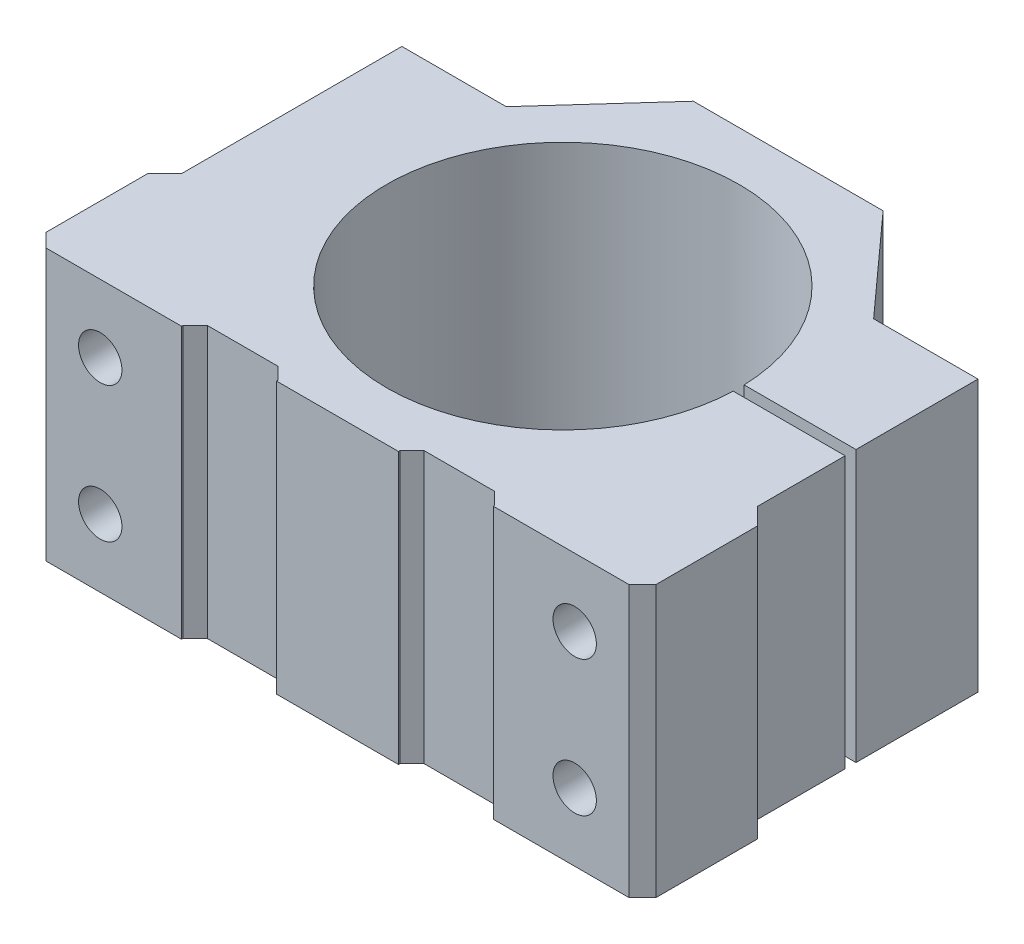
from build123d import *

# Parameters (mm, degrees)
CROQUIS1_R              = 26
SALIENTE_EXTRUIR1_DEPTH = 40
CROQUIS2_R              = 3.2
CORTAR_EXTRUIR1_DEPTH   = 67.5
CORTAR_EXTRUIR2_REACH   = 89.5
CROQUIS3_W              = 1.6
CROQUIS3_H              = 40


with BuildPart() as part:
    # Croquis1 → Saliente-Extruir1 (new body)
    with BuildSketch(Plane(origin=(0, 0, 0), x_dir=(1, 0, 0), z_dir=(0, 1, 0))):
        Polygon((-42.5, 18.75), (-42.5, -13.75), (-45, -16.25), (-45, -31.25), (-43, -33.25), (-23, -33.25), (-23, -33.05), (-21.2, -31.25), (-10.8, -31.25), (-9, -33.05), (-9, -33.25), (9, -33.25), (9, -33.05), (10.8, -31.25), (21.2, -31.25), (23, -33.05), (23, -33.25), (43, -33.25), (45, -31.25), (45, -16.25), (42.5, -13.75), (42.5, 18.75), (27.1, 18.75), (14, 33.25), (-14, 33.25), (-27.1, 18.75), align=None)
        Circle(CROQUIS1_R, mode=Mode.SUBTRACT)
    extrude(amount=SALIENTE_EXTRUIR1_DEPTH)

    # Croquis2 → Cortar-Extruir1 (cut, through all)
    with BuildSketch(Plane(origin=(0, 0, -33.25), x_dir=(-1, 0, 0), z_dir=(0, 0, -1))):
        with Locations((-35, 30)):
            Circle(CROQUIS2_R)
        with Locations((-35, 10)):
            Circle(CROQUIS2_R)
        with Locations((35, 10)):
            Circle(CROQUIS2_R)
        with Locations((35, 30)):
            Circle(CROQUIS2_R)
    extrude(amount=-CORTAR_EXTRUIR1_DEPTH, mode=Mode.SUBTRACT)

    # Croquis3 → Cortar-Extruir2 (cut, up to next)
    with BuildSketch(Plane(origin=(42.5, 0, 0), x_dir=(0, 0, -1), z_dir=(1, 0, 0)), mode=Mode.PRIVATE) as cortar_extruir2_sk1:
        with Locations((-0.05, 20)):
            Rectangle(CROQUIS3_W, CROQUIS3_H)
    cortar_extruir2_tool1 = extrude(cortar_extruir2_sk1.sketch, amount=-CORTAR_EXTRUIR2_REACH, mode=Mode.PRIVATE) & part.part
    add(cortar_extruir2_tool1.solids().sort_by_distance((42.5, 20, 0.05))[0], mode=Mode.SUBTRACT)


solid = part.part
